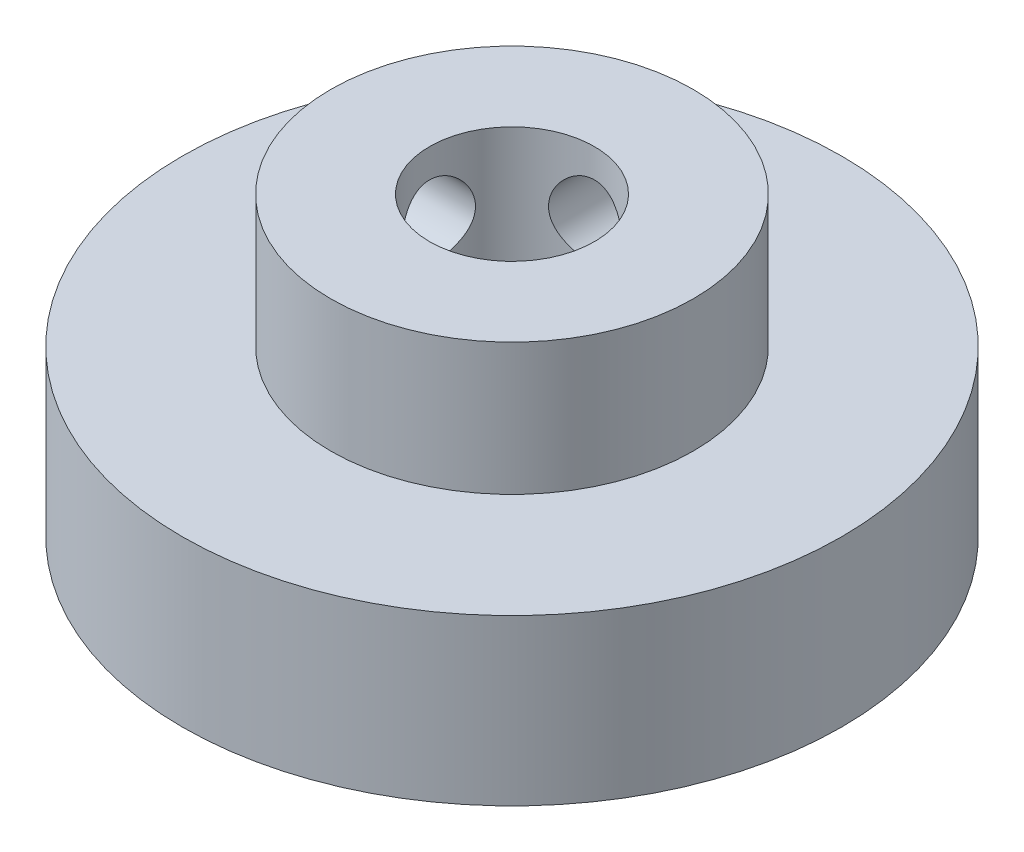
from build123d import *

# Parameters (mm, degrees)
SKETCH1_R               = 11
BOSS_EXTRUDE1_DEPTH     = 18
SKETCH2_R               = 20
BOSS_EXTRUDE2_DEPTH     = 10
SKETCH3_R               = 5
CUT_EXTRUDE1_DEPTH      = 1
CUT_EXTRUDE1_DEPTH_BACK = 19
SKETCH4_R               = 2.25
CUT_EXTRUDE2_DEPTH      = 7
CIRPATTERN1_COUNT       = 4
SKETCH5_R               = 2.25
CUT_EXTRUDE3_DEPTH      = 21
CIRPATTERN2_COUNT       = 2
CIRPATTERN2_ANGLE       = 90


with BuildPart() as part:
    # Sketch1 → Boss-Extrude1 (new body)
    with BuildSketch(Plane(origin=(0, 0, 0), x_dir=(1, 0, 0), z_dir=(0, 1, 0))):
        Circle(SKETCH1_R)
    extrude(amount=BOSS_EXTRUDE1_DEPTH)

    # Sketch2 → Boss-Extrude2 (add)
    with BuildSketch(Plane.XZ):
        Circle(SKETCH2_R)
    extrude(amount=-BOSS_EXTRUDE2_DEPTH)

    # Sketch3 → Cut-Extrude1 (cut, two sides)
    with BuildSketch(Plane(origin=(0, 18, 0), x_dir=(1, 0, 0), z_dir=(0, 1, 0))) as cut_extrude1_sk:
        Circle(SKETCH3_R)
    extrude(amount=CUT_EXTRUDE1_DEPTH, mode=Mode.SUBTRACT)
    extrude(cut_extrude1_sk.sketch, amount=-CUT_EXTRUDE1_DEPTH_BACK, mode=Mode.SUBTRACT)

    # Sketch4 → Cut-Extrude2 (cut)
    with BuildSketch(Plane.XZ):
        with Locations((-10.606601718, 10.606601718)):
            Circle(SKETCH4_R)
    cut_extrude2 = extrude(amount=-CUT_EXTRUDE2_DEPTH, mode=Mode.SUBTRACT)

    # CirPattern1: Cut-Extrude2 ×4 about axis
    cirpattern1_axis = Axis((0, 0, 0), (0, 1, 0))
    for i in range(1, CIRPATTERN1_COUNT):
        add(cut_extrude2.rotate(cirpattern1_axis, i * 360 / CIRPATTERN1_COUNT), mode=Mode.SUBTRACT)

    # Sketch5 → Cut-Extrude3 (cut, through all)
    with BuildSketch(Plane.XY):
        with Locations((0, 14)):
            Circle(SKETCH5_R)
        with Locations((0, 5)):
            Circle(SKETCH5_R)
    cut_extrude3 = extrude(amount=-CUT_EXTRUDE3_DEPTH, mode=Mode.SUBTRACT)

    # CirPattern2: Cut-Extrude3 ×2 about axis
    cirpattern2_axis = Axis((0, 18, 0), (0, 1, 0))
    for i in range(1, CIRPATTERN2_COUNT):
        add(cut_extrude3.rotate(cirpattern2_axis, i * CIRPATTERN2_ANGLE / (CIRPATTERN2_COUNT - 1)), mode=Mode.SUBTRACT)


solid = part.part
